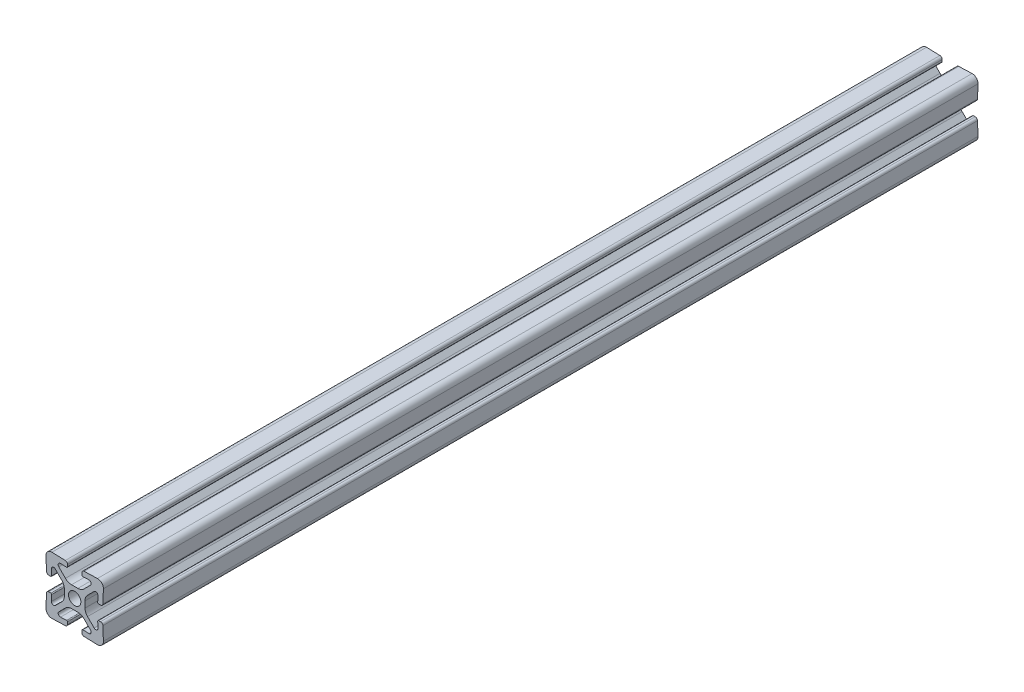
from build123d import *

# Parameters (mm, degrees)
BOSS_EXTRUDE1_DEPTH = 152.4
CIRPATTERN1_COUNT   = 4


with BuildPart() as part:
    # Sketch3 → Boss-Extrude1 (new body, symmetric)
    with BuildSketch(Plane.XY):
        with BuildLine():
            Line((-2.524916986, 8.30911066), (-2.500487338, 9.008684239))
            ThreePointArc((-2.500487338, 9.008684239), (-2.714917039, 9.582202525), (-3.272080403, 9.836116498))
            Line((-3.272080403, 9.836116498), (-7.930201007, 9.998781654))
            ThreePointArc((-7.930201007, 9.998781654), (-9.414213562, 9.414213562), (-9.998781654, 7.930201007))
            Line((-9.998781654, 7.930201007), (-9.836116498, 3.272080403))
            ThreePointArc((-9.836116498, 3.272080403), (-9.582202525, 2.714917039), (-9.008684239, 2.500487338))
            Line((-9.008684239, 2.500487338), (-8.30911066, 2.524916986))
            ThreePointArc((-8.30911066, 2.524916986), (-8.100174399, 2.620134726), (-8.019763261, 2.835204083))
            Line((-8.019763261, 2.835204083), (-8.093719461, 4.953032548))
            ThreePointArc((-8.093719461, 4.953032548), (-7.631170264, 5.686128657), (-6.779559917, 5.52444538))
            Line((-6.779559917, 5.52444538), (-4.478679656, 3.22356512))
            ThreePointArc((-4.478679656, 3.22356512), (-3.828361402, 2.250295073), (-3.6, 1.102244776))
            Line((-3.6, 1.102244776), (-3.6, 0))
            Line((-3.6, 0), (-2.15, 0))
            ThreePointArc((-2.15, 0), (-1.52027958, 1.52027958), (0, 2.15))
            Line((0, 2.15), (0, 3.6))
            Line((0, 3.6), (-1.102244776, 3.6))
            ThreePointArc((-1.102244776, 3.6), (-2.250295073, 3.828361402), (-3.22356512, 4.478679656))
            Line((-3.22356512, 4.478679656), (-5.52444538, 6.779559917))
            ThreePointArc((-5.52444538, 6.779559917), (-5.686128657, 7.631170264), (-4.953032548, 8.093719461))
            Line((-4.953032548, 8.093719461), (-2.835204083, 8.019763261))
            ThreePointArc((-2.835204083, 8.019763261), (-2.620134726, 8.100174399), (-2.524916986, 8.30911066))
        make_face()
    boss_extrude1 = extrude(amount=BOSS_EXTRUDE1_DEPTH, both=True)

    # CirPattern1: Boss-Extrude1 ×4 about axis
    cirpattern1_axis = Axis((0, 0, 0), (0, 0, 1))
    for i in range(1, CIRPATTERN1_COUNT):
        add(boss_extrude1.rotate(cirpattern1_axis, i * 360 / CIRPATTERN1_COUNT))


solid = part.part
